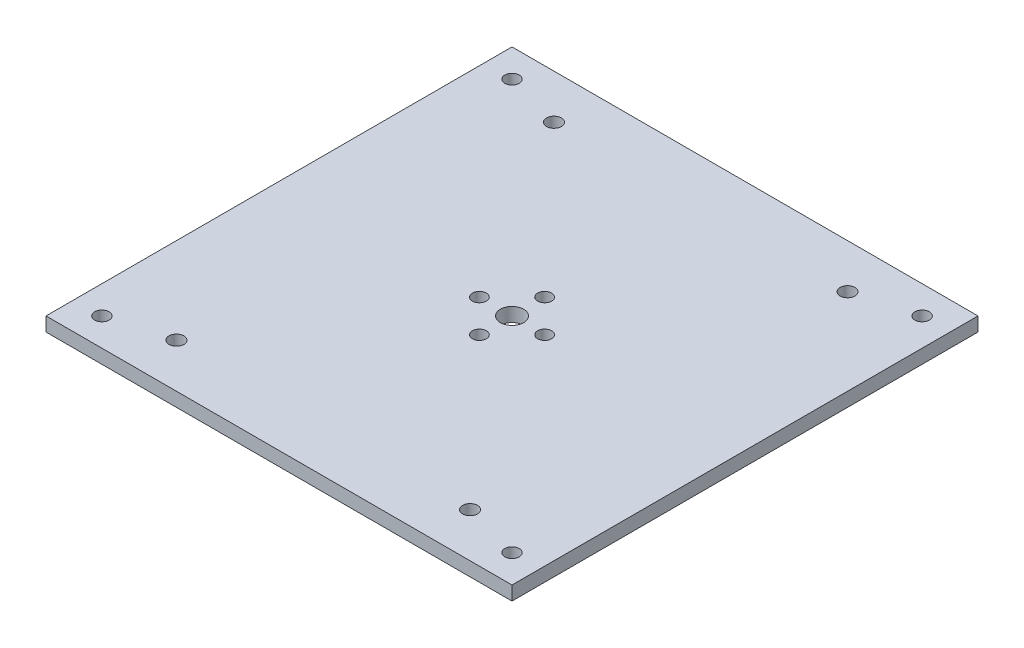
from build123d import *

# Parameters (mm, degrees)
CROQUIS1_W              = 100
CROQUIS1_H              = 100
SALIENTE_EXTRUIR1_DEPTH = 3
CROQUIS6_R              = 1.55
CORTAR_EXTRUIR4_DEPTH   = 10
CROQUIS7_R              = 1.6
CORTAR_EXTRUIR5_DEPTH   = 10
CROQUIS8_R              = 2.5
CROQUIS8_R_2            = 1.5
CORTAR_EXTRUIR6_DEPTH   = 10


with BuildPart() as part:
    # Croquis1 → Saliente-Extruir1 (new body)
    with BuildSketch(Plane(origin=(0, 0, 0), x_dir=(1, 0, 0), z_dir=(0, 1, 0))):
        Rectangle(CROQUIS1_W, CROQUIS1_H)
    extrude(amount=SALIENTE_EXTRUIR1_DEPTH)

    # Croquis6 → Cortar-Extruir4 (cut)
    with BuildSketch(Plane(origin=(0, 3, 0), x_dir=(1, 0, 0), z_dir=(0, 1, 0))):
        with Locations(Location((-44, 44, 0), (0, 0, 270))):  # turned: the seam where the file's is
            Circle(CROQUIS6_R)
        with Locations(Location((44, 44, 0), (0, 0, 270))):  # turned: the seam where the file's is
            Circle(CROQUIS6_R)
        with Locations(Location((44, -44, 0), (0, 0, 270))):  # turned: the seam where the file's is
            Circle(CROQUIS6_R)
        with Locations(Location((-44, -44, 0), (0, 0, 270))):  # turned: the seam where the file's is
            Circle(CROQUIS6_R)
    extrude(amount=-CORTAR_EXTRUIR4_DEPTH, mode=Mode.SUBTRACT)

    # Croquis7 → Cortar-Extruir5 (cut)
    with BuildSketch(Plane(origin=(0, 3, 0), x_dir=(1, 0, 0), z_dir=(0, 1, 0))):
        with Locations(Location((-31.5, 40.5, 0), (0, 0, 270))):  # turned: the seam where the file's is
            Circle(CROQUIS7_R)
        with Locations(Location((31.5, 40.5, 0), (0, 0, 270))):  # turned: the seam where the file's is
            Circle(CROQUIS7_R)
        with Locations(Location((-31.5, -40.5, 0), (0, 0, 270))):  # turned: the seam where the file's is
            Circle(CROQUIS7_R)
        with Locations(Location((31.5, -40.5, 0), (0, 0, 270))):  # turned: the seam where the file's is
            Circle(CROQUIS7_R)
    extrude(amount=-CORTAR_EXTRUIR5_DEPTH, mode=Mode.SUBTRACT)

    # Croquis8 → Cortar-Extruir6 (cut)
    with BuildSketch(Plane(origin=(0, 3, 0), x_dir=(1, 0, 0), z_dir=(0, 1, 0))):
        with Locations(Location((0, 0, 0), (0, 0, 270))):  # turned: the seam where the file's is
            Circle(CROQUIS8_R)
        with Locations(Location((0, 7, 0), (0, 0, 270))):  # turned: the seam where the file's is
            Circle(CROQUIS8_R_2)
        with Locations(Location((7, 0, 0), (0, 0, 270))):  # turned: the seam where the file's is
            Circle(CROQUIS8_R_2)
        with Locations(Location((0, -7, 0), (0, 0, 270))):  # turned: the seam where the file's is
            Circle(CROQUIS8_R_2)
        with Locations(Location((-7, 0, 0), (0, 0, 270))):  # turned: the seam where the file's is
            Circle(CROQUIS8_R_2)
    extrude(amount=-CORTAR_EXTRUIR6_DEPTH, mode=Mode.SUBTRACT)


solid = part.part
